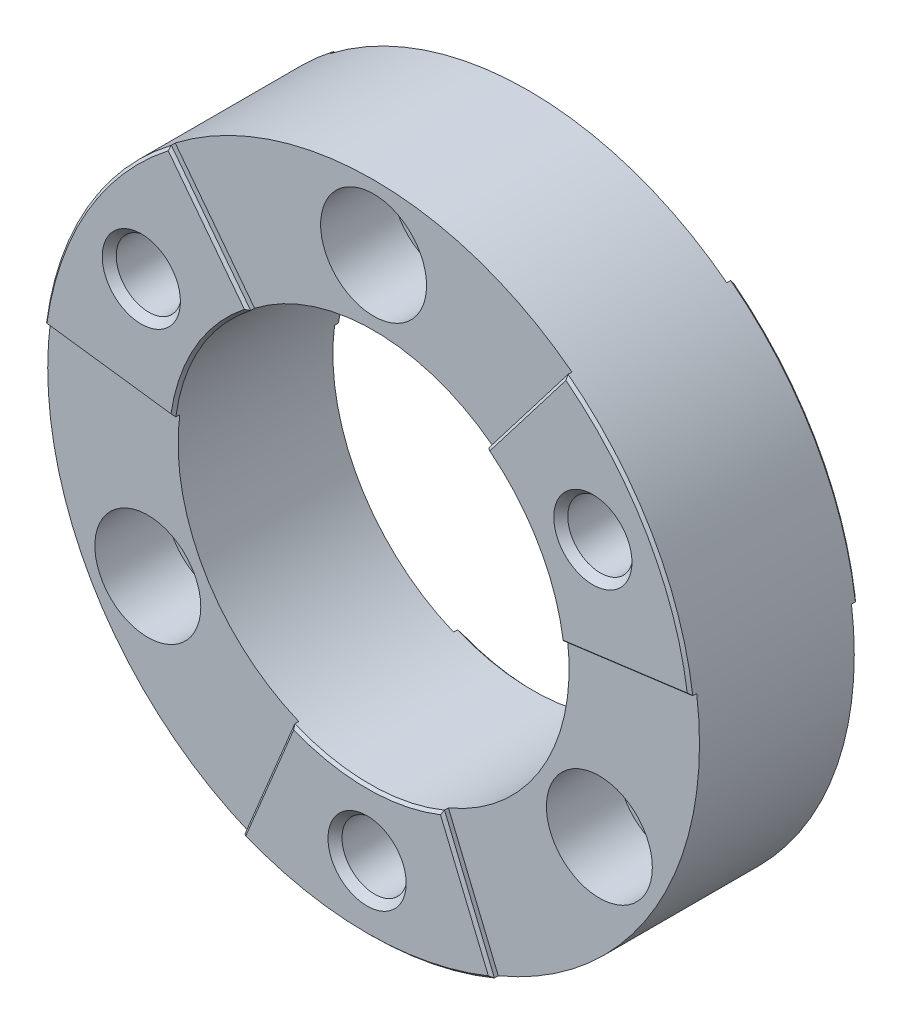
from build123d import *

# Parameters (mm, degrees)
SKETCH1_R                                        = 63.5
EXTRUDE1_DEPTH                                   = 32.7025
SKETCH2_R                                        = 38.1
CUT_EXTRUDE1_DEPTH                               = 33.7025
CUT_EXTRUDE2_DEPTH                               = 1.27
CUT_EXTRUDE3_DEPTH                               = 1.27
CBORE_FOR_1_2_SOCKET_HEAD_CAP_SCREW1_D           = 13.89126
CBORE_FOR_1_2_SOCKET_HEAD_CAP_SCREW1_CBORE_D     = 20.6375
CBORE_FOR_1_2_SOCKET_HEAD_CAP_SCREW1_CBORE_DEPTH = 13.97
F_1_2_20_TAPPED_HOLE1_AT_2_COUNT                 = 2
F_1_2_20_TAPPED_HOLE1_AT_2_PITCH                 = 87.988181024
F_1_2_20_TAPPED_HOLE1_AT_3_COUNT                 = 2
F_1_2_20_TAPPED_HOLE1_AT_3_PITCH                 = 87.988181024
CHAMFER1_SIZE                                    = 0.508


with BuildPart() as part:
    # Sketch1 → Extrude1 (new body)
    with BuildSketch(Plane.XY):
        with Locations(Location((0, 0, 0), (0, 0, 172.5))):  # turned: the seam where the file's is
            Circle(SKETCH1_R)
    extrude(amount=EXTRUDE1_DEPTH)

    # Sketch2 → Cut-Extrude1 (cut, through all)
    with BuildSketch(Plane.XY.offset(32.7025)):
        with Locations(Location((0, 0, 0), (0, 0, 7.5))):  # turned: the seam where the file's is
            Circle(SKETCH2_R)
    extrude(amount=-CUT_EXTRUDE1_DEPTH, mode=Mode.SUBTRACT)

    # Sketch3 → Cut-Extrude2 (cut)
    with BuildSketch(Plane.XY.offset(32.7025)):
        with BuildLine():
            Line((-38.656350742, 50.377937108), (-23.193810445, 30.226762265))
            ThreePointArc((-23.193810445, 30.226762265), (0, 38.1), (23.193810445, 30.226762265))
            Line((23.193810445, 30.226762265), (38.656350742, 50.377937108))
            ThreePointArc((38.656350742, 50.377937108), (0, 63.5), (-38.656350742, 50.377937108))
        make_face()
        with BuildLine():
            Line((-62.956748697, 8.288413206), (-37.774049218, 4.973047924))
            ThreePointArc((-37.774049218, 4.973047924), (-32.995567884, -19.05), (-14.580238773, -35.199810189))
            Line((-14.580238773, -35.199810189), (-24.300397955, -58.666350314))
            ThreePointArc((-24.300397955, -58.666350314), (-54.99261314, -31.75), (-62.956748697, 8.288413206))
        make_face()
        with BuildLine():
            Line((24.300397955, -58.666350314), (14.580238773, -35.199810189))
            ThreePointArc((14.580238773, -35.199810189), (32.995567884, -19.05), (37.774049218, 4.973047924))
            Line((37.774049218, 4.973047924), (62.956748697, 8.288413206))
            ThreePointArc((62.956748697, 8.288413206), (54.99261314, -31.75), (24.300397955, -58.666350314))
        make_face()
    extrude(amount=-CUT_EXTRUDE2_DEPTH, mode=Mode.SUBTRACT)

    # Sketch4 → Cut-Extrude3 (cut)
    with BuildSketch(Plane(origin=(0, 0, 0), x_dir=(-1, 0, 0), z_dir=(0, 0, -1))):
        with BuildLine():
            Line((24.300397955, -58.666350314), (14.580238773, -35.199810189))
            ThreePointArc((14.580238773, -35.199810189), (32.995567884, -19.05), (37.774049218, 4.973047924))
            Line((37.774049218, 4.973047924), (62.956748697, 8.288413206))
            ThreePointArc((62.956748697, 8.288413206), (54.99261314, -31.75), (24.300397955, -58.666350314))
        make_face()
        with BuildLine():
            Line((-24.300397955, -58.666350314), (-14.580238773, -35.199810189))
            ThreePointArc((-14.580238773, -35.199810189), (-32.995567884, -19.05), (-37.774049218, 4.973047924))
            Line((-37.774049218, 4.973047924), (-62.956748697, 8.288413206))
            ThreePointArc((-62.956748697, 8.288413206), (-54.99261314, -31.75), (-24.300397955, -58.666350314))
        make_face()
        with BuildLine():
            Line((-38.656350742, 50.377937108), (-23.193810445, 30.226762265))
            ThreePointArc((-23.193810445, 30.226762265), (0, 38.1), (23.193810445, 30.226762265))
            Line((23.193810445, 30.226762265), (38.656350742, 50.377937108))
            ThreePointArc((38.656350742, 50.377937108), (0, 63.5), (-38.656350742, 50.377937108))
        make_face()
    extrude(amount=-CUT_EXTRUDE3_DEPTH, mode=Mode.SUBTRACT)

    # CBORE for 1_2 Socket Head Cap Screw1 (through all)
    with Locations(Plane.XY.offset(31.4325)):
        with Locations((-43.994090512, -25.4), (0, 50.8), (43.994090512, -25.4)):
            CounterBoreHole(CBORE_FOR_1_2_SOCKET_HEAD_CAP_SCREW1_D / 2, CBORE_FOR_1_2_SOCKET_HEAD_CAP_SCREW1_CBORE_D / 2, CBORE_FOR_1_2_SOCKET_HEAD_CAP_SCREW1_CBORE_DEPTH)

    # Sketch9 → 1_2-20 Tapped Hole1 (revolve, cut)
    with BuildSketch(Plane(origin=(0, -50.8, 32.7025), x_dir=(0, -1, 0), z_dir=(1, 0, 0))):
        Polygon((0, 0), (0, 32.7025), (7.62, 32.7025), (6.35, 31.241532123), (6.35, 1.460967877), (7.62, 0), align=None)
    f_1_2_20_tapped_hole1 = revolve(axis=Axis((0, -50.8, 39.0525), (0, 0, -1)), mode=Mode.SUBTRACT)

    # 1_2-20 Tapped Hole1 at 2: 1_2-20 Tapped Hole1 ×2
    with Locations(*[Vector(-0.5, 0.866025404, 0) * (i * F_1_2_20_TAPPED_HOLE1_AT_2_PITCH) for i in range(1, F_1_2_20_TAPPED_HOLE1_AT_2_COUNT)]):
        add(f_1_2_20_tapped_hole1, mode=Mode.SUBTRACT)

    # 1_2-20 Tapped Hole1 at 3: 1_2-20 Tapped Hole1 ×2
    with Locations(*[Vector(0.5, 0.866025404, 0) * (i * F_1_2_20_TAPPED_HOLE1_AT_3_PITCH) for i in range(1, F_1_2_20_TAPPED_HOLE1_AT_3_COUNT)]):
        add(f_1_2_20_tapped_hole1, mode=Mode.SUBTRACT)

    # Chamfer1
    chamfer1_edges = [part.edges().sort_by_distance(p)[0] for p in [
        (-54.99261314, 31.75, 32.7025),
        (54.99261314, 31.75, 32.7025),
        (0, -63.5, 32.7025),
        (0, -63.5, 0),
        (54.99261314, 31.75, 0),
        (-54.99261314, 31.75, 0),
        (-50.365398958, 6.630730565, 0),
        (-50.365398958, 6.630730565, 32.7025),
        (-30.925080594, 40.302349687, 32.7025),
        (-32.995567884, 19.05, 32.7025),
        (30.925080594, 40.302349687, 32.7025),
        (50.365398958, 6.630730565, 32.7025),
        (32.995567884, 19.05, 32.7025),
        (19.440318364, -46.933080252, 32.7025),
        (-19.440318364, -46.933080252, 32.7025),
        (0, -38.1, 32.7025),
        (-19.440318364, -46.933080252, 0),
        (0, -38.1, 0),
        (19.440318364, -46.933080252, 0),
        (50.365398958, 6.630730565, 0),
        (30.925080594, 40.302349687, 0),
        (32.995567884, 19.05, 0),
        (-30.925080594, 40.302349687, 0),
        (-32.995567884, 19.05, 0),
    ]]
    chamfer(chamfer1_edges, length=CHAMFER1_SIZE)


solid = part.part
